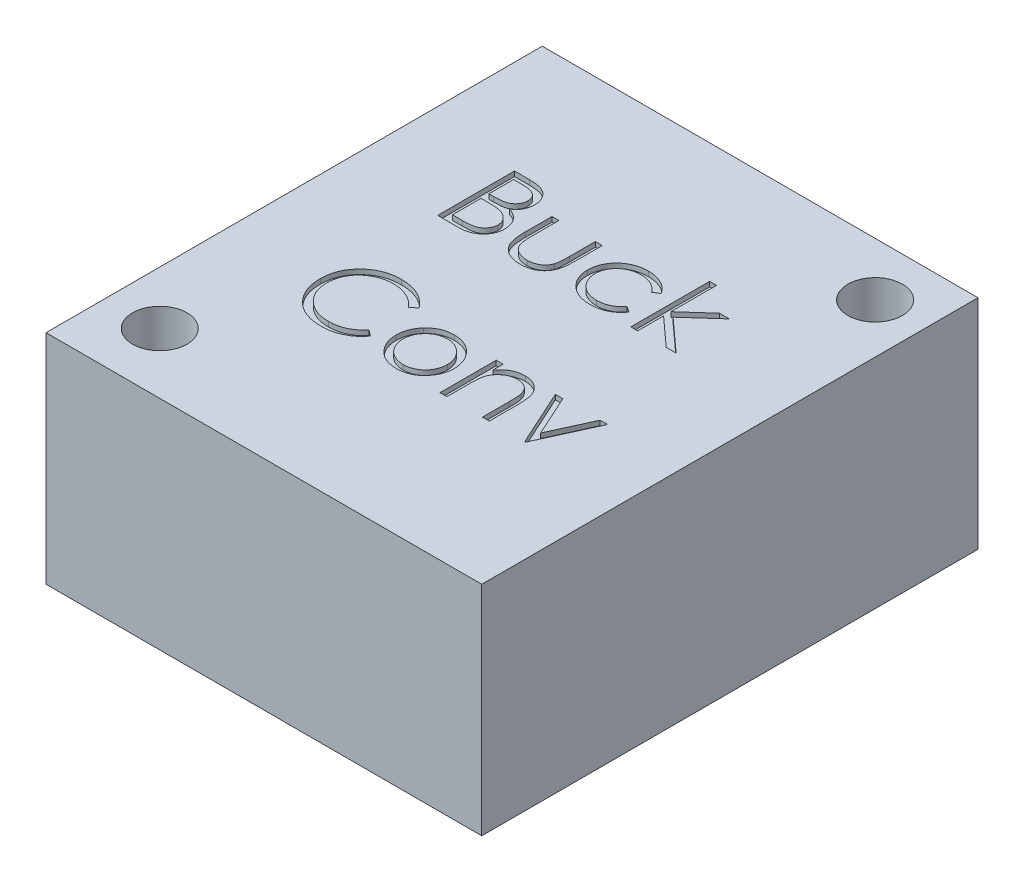
from build123d import *

# Parameters (mm, degrees)
SKETCH1_W           = 18
SKETCH1_H           = 20.5
SKETCH1_R           = 1.125
BOSS_EXTRUDE1_DEPTH = 9
CUT_EXTRUDE1_DEPTH  = 0.2


with BuildPart() as part:
    # Sketch1 → Boss-Extrude1 (new body)
    with BuildSketch(Plane(origin=(0, 0, 0), x_dir=(1, 0, 0), z_dir=(0, 1, 0))):
        Rectangle(SKETCH1_W, SKETCH1_H)
        with Locations((6.95, 8.05)):
            Circle(SKETCH1_R, mode=Mode.SUBTRACT)
        with Locations((-6.8, -7.75)):
            Circle(SKETCH1_R, mode=Mode.SUBTRACT)
    extrude(amount=BOSS_EXTRUDE1_DEPTH)

    # Sketch3 → Cut-Extrude1 (cut)
    with BuildSketch(Plane(origin=(0, 9, 0), x_dir=(1, 0, 0), z_dir=(0, 1, 0))):
        with BuildLine():
            Line((-5.106587344, 5.210805031), (-4.487106175, 5.210805031))
            add(Edge.make_bspline(
                [(-4.487106175, 5.210805031), (-4.456781769, 5.210645601), (-4.398005525, 5.210336584), (-4.312535031, 5.20554403), (-4.232480753, 5.199009272), (-4.157819474, 5.188640545), (-4.088585694, 5.176129433), (-4.024570766, 5.1609785), (-3.965978252, 5.1428115), (-3.896025984, 5.113922374), (-3.816269385, 5.070993499), (-3.729910843, 5.007558301), (-3.656065569, 4.929968138), (-3.592396552, 4.842444586), (-3.541776965, 4.746164279), (-3.505156245, 4.643422015), (-3.481971601, 4.535543006), (-3.479587236, 4.461480981), (-3.478382216, 4.424051225)],
                knots=[0, 0, 0, 0, 9.0959e-05, 0.000176302, 0.000256745, 0.000331852, 0.000402335, 0.000467743, 0.000529095, 0.000586142, 0.000694565, 0.000800018, 0.00090617, 0.001014562, 0.001123809, 0.001231237, 0.001341005, 0.001453163, 0.001453163, 0.001453163, 0.001453163], degree=3))
            add(Edge.make_bspline(
                [(-3.478382216, 4.424051225), (-3.479373922, 4.388987835), (-3.481322716, 4.320084968), (-3.499957933, 4.21930674), (-3.529132254, 4.123375277), (-3.569686301, 4.032640685), (-3.622393112, 3.94915305), (-3.684857444, 3.872238887), (-3.760219972, 3.805154714), (-3.816683483, 3.767650795), (-3.845364388, 3.748600504)],
                knots=[0, 0, 0, 0, 0.000105099, 0.000206529, 0.000306317, 0.000405381, 0.000503676, 0.000601724, 0.00070171, 0.000804929, 0.000804929, 0.000804929, 0.000804929], degree=3))
            add(Edge.make_bspline(
                [(-3.845364388, 3.748600504), (-3.809296, 3.734752969), (-3.740288239, 3.708259205), (-3.645323071, 3.661418463), (-3.563503461, 3.610471405), (-3.494200336, 3.554834656), (-3.434929749, 3.49486452), (-3.383174581, 3.429681667), (-3.33901362, 3.358435793), (-3.301174039, 3.281869729), (-3.271647667, 3.20076529), (-3.24953524, 3.115883229), (-3.236864768, 3.027527918), (-3.235061694, 2.96739761), (-3.234151447, 2.93704201)],
                knots=[0, 0, 0, 0, 0.000115862, 0.000221672, 0.000317136, 0.000404447, 0.000487649, 0.000569596, 0.000653599, 0.000738647, 0.000825372, 0.000912066, 0.001001383, 0.001092443, 0.001092443, 0.001092443, 0.001092443], degree=3))
            add(Edge.make_bspline(
                [(-3.234151447, 2.93704201), (-3.235037586, 2.906047776), (-3.236781089, 2.845065753), (-3.249644349, 2.755480738), (-3.271424039, 2.669869179), (-3.301424293, 2.587677335), (-3.340578679, 2.509064213), (-3.388229046, 2.433940752), (-3.445044822, 2.363061752), (-3.508601853, 2.295639608), (-3.580503942, 2.235017258), (-3.658078948, 2.18102801), (-3.742303824, 2.136626939), (-3.831795276, 2.099328834), (-3.927557191, 2.070838018), (-4.029159557, 2.050905755), (-4.136514745, 2.037475471), (-4.21018359, 2.036371293), (-4.247963546, 2.035805031)],
                knots=[0, 0, 0, 0, 9.2965e-05, 0.000182912, 0.000270839, 0.000357564, 0.000444886, 0.000533812, 0.000623905, 0.000717027, 0.000811331, 0.000905539, 0.001000006, 0.001096388, 0.001195991, 0.001299146, 0.001406751, 0.001520027, 0.001520027, 0.001520027, 0.001520027], degree=3))
            Line((-4.247963546, 2.035805031), (-5.106587344, 2.035805031))
            Line((-5.106587344, 2.035805031), (-5.106587344, 5.210805031))
        make_face()
        with BuildLine():
            Line((-4.821651447, 4.885164006), (-4.821651447, 3.867535801))
            Line((-4.821651447, 3.867535801), (-4.630210141, 3.867535801))
            add(Edge.make_bspline(
                [(-4.630210141, 3.867535801), (-4.602225877, 3.867898588), (-4.548154575, 3.868599567), (-4.469850097, 3.870607543), (-4.397165259, 3.876230054), (-4.330225525, 3.881850949), (-4.269136308, 3.890990039), (-4.214032948, 3.901868608), (-4.164050649, 3.913373814), (-4.106411205, 3.93294042), (-4.041030744, 3.961858026), (-3.971332142, 4.006736048), (-3.909887302, 4.060188855), (-3.858001282, 4.12186637), (-3.815536591, 4.189780696), (-3.786042006, 4.262848223), (-3.76604197, 4.339247914), (-3.764235367, 4.391697329), (-3.763318114, 4.418327067)],
                knots=[0, 0, 0, 0, 8.3964e-05, 0.000162235, 0.00023492, 0.000302637, 0.000363711, 0.000420091, 0.000471151, 0.00051741, 0.000602525, 0.000684916, 0.00076515, 0.000845934, 0.000925893, 0.001004319, 0.001081603, 0.001161311, 0.001161311, 0.001161311, 0.001161311], degree=3))
            add(Edge.make_bspline(
                [(-3.763318114, 4.418327067), (-3.763795434, 4.435949016), (-3.764731751, 4.470516395), (-3.772400104, 4.520907595), (-3.785433546, 4.568300142), (-3.802174227, 4.613343514), (-3.825568251, 4.654629264), (-3.85311225, 4.693584877), (-3.886391412, 4.728883727), (-3.92427126, 4.761876058), (-3.967821939, 4.791126451), (-4.017017468, 4.816744857), (-4.072523433, 4.837373991), (-4.13340438, 4.855440786), (-4.200597438, 4.868130167), (-4.273327211, 4.878701454), (-4.35218942, 4.884083299), (-4.406749621, 4.884795735), (-4.434952729, 4.885164006)],
                knots=[0, 0, 0, 0, 5.2851e-05, 0.000103672, 0.000152426, 0.000200145, 0.000247403, 0.000294352, 0.000342957, 0.000392558, 0.000444773, 0.00049996, 0.000558547, 0.000622148, 0.000690253, 0.000763469, 0.000842543, 0.000927155, 0.000927155, 0.000927155, 0.000927155], degree=3))
            Line((-4.434952729, 4.885164006), (-4.821651447, 4.885164006))
        make_face(mode=Mode.SUBTRACT)
        with BuildLine():
            Line((-4.821651447, 3.541894775), (-4.821651447, 2.361446057))
            Line((-4.821651447, 2.361446057), (-4.4158722, 2.361446057))
            add(Edge.make_bspline(
                [(-4.4158722, 2.361446057), (-4.38682646, 2.361794171), (-4.330844626, 2.362465114), (-4.250017081, 2.36465546), (-4.175102409, 2.369637739), (-4.106442457, 2.377480759), (-4.043295832, 2.385988352), (-3.986420058, 2.397428586), (-3.93535409, 2.410535857), (-3.876140968, 2.430796142), (-3.809462786, 2.462270798), (-3.737607223, 2.509727275), (-3.673720582, 2.566263418), (-3.619468669, 2.631696462), (-3.575006886, 2.70284488), (-3.542662295, 2.77826959), (-3.522713446, 2.856724318), (-3.520298478, 2.910215551), (-3.519087344, 2.93704201)],
                knots=[0, 0, 0, 0, 8.7144e-05, 0.000167958, 0.000242546, 0.000312291, 0.000375253, 0.000433628, 0.000486234, 0.000533299, 0.000621212, 0.00070659, 0.000790835, 0.000876178, 0.000960721, 0.001041645, 0.001121551, 0.001201941, 0.001201941, 0.001201941, 0.001201941], degree=3))
            add(Edge.make_bspline(
                [(-3.519087344, 2.93704201), (-3.519337811, 2.953818112), (-3.519834703, 2.987099716), (-3.52732826, 3.036009066), (-3.538226557, 3.083385394), (-3.552315786, 3.129357344), (-3.572834874, 3.173093764), (-3.596789383, 3.215459657), (-3.624875797, 3.256511028), (-3.668640147, 3.308410715), (-3.732296162, 3.368206863), (-3.822744451, 3.426751597), (-3.925589321, 3.473966393), (-4.000181404, 3.494013775), (-4.038713747, 3.504369735)],
                knots=[0, 0, 0, 0, 5.0282e-05, 9.9752e-05, 0.000148043, 0.000196116, 0.000243648, 0.000292638, 0.000342035, 0.000392605, 0.000496106, 0.000602654, 0.000714508, 0.000834032, 0.000834032, 0.000834032, 0.000834032], degree=3))
            add(Edge.make_bspline(
                [(-4.038713747, 3.504369735), (-4.054161569, 3.50750399), (-4.087655635, 3.5142997), (-4.142272512, 3.521473117), (-4.204625764, 3.527863993), (-4.274859374, 3.532591257), (-4.353062202, 3.537477622), (-4.439401264, 3.539377924), (-4.53352397, 3.54164511), (-4.598831337, 3.541809424), (-4.632754211, 3.541894775)],
                knots=[0, 0, 0, 0, 4.7275e-05, 0.000102503, 0.000165156, 0.000235303, 0.00031366, 0.000400195, 0.000494345, 0.00059611, 0.00059611, 0.00059611, 0.00059611], degree=3))
            Line((-4.632754211, 3.541894775), (-4.821651447, 3.541894775))
        make_face(mode=Mode.SUBTRACT)
        with BuildLine():
            Line((-2.70498478, 4.355997339), (-2.420048883, 4.355997339))
            Line((-2.420048883, 4.355997339), (-2.420048883, 3.279855512))
            add(Edge.make_bspline(
                [(-2.420048883, 3.279855512), (-2.419920155, 3.248266304), (-2.419673904, 3.187837628), (-2.418003908, 3.10088328), (-2.414075894, 3.021583834), (-2.409164782, 2.94989348), (-2.40284913, 2.885824346), (-2.395334939, 2.829600215), (-2.386936228, 2.780583491), (-2.378715051, 2.751062018), (-2.374891631, 2.737332475)],
                knots=[0, 0, 0, 0, 9.4769e-05, 0.000181288, 0.000260882, 0.000332932, 0.000396851, 0.000453969, 0.000503119, 0.000545851, 0.000545851, 0.000545851, 0.000545851], degree=3))
            add(Edge.make_bspline(
                [(-2.374891631, 2.737332475), (-2.368758026, 2.720076014), (-2.356618331, 2.685921848), (-2.334598813, 2.636583251), (-2.307358822, 2.590885673), (-2.277550264, 2.547066979), (-2.243170087, 2.506425176), (-2.204653281, 2.469028898), (-2.163289166, 2.433465187), (-2.101825681, 2.391387554), (-2.017770489, 2.346288647), (-1.907414061, 2.307376012), (-1.787758085, 2.284120661), (-1.705058661, 2.281422587), (-1.662551888, 2.280035801)],
                knots=[0, 0, 0, 0, 5.4937e-05, 0.000108733, 0.000161748, 0.000214322, 0.000267581, 0.000321101, 0.000375256, 0.000431008, 0.000544257, 0.000660328, 0.000780822, 0.000908255, 0.000908255, 0.000908255, 0.000908255], degree=3))
            add(Edge.make_bspline(
                [(-1.662551888, 2.280035801), (-1.620049063, 2.281452076), (-1.537813961, 2.284192307), (-1.419472667, 2.306674517), (-1.311294599, 2.344235392), (-1.214365521, 2.396674973), (-1.129125081, 2.46084813), (-1.058091786, 2.536148978), (-0.999483777, 2.620195207), (-0.973893802, 2.682900803), (-0.961024444, 2.714435841)],
                knots=[0, 0, 0, 0, 0.000127432, 0.000246558, 0.000359807, 0.000469652, 0.000575869, 0.000678443, 0.000779171, 0.000881077, 0.000881077, 0.000881077, 0.000881077], degree=3))
            add(Edge.make_bspline(
                [(-0.961024444, 2.714435841), (-0.957219678, 2.727105269), (-0.94880827, 2.75511428), (-0.939770994, 2.802630195), (-0.931629875, 2.859294514), (-0.92467828, 2.925478032), (-0.919720596, 3.001007792), (-0.917048129, 3.08586019), (-0.914028908, 3.179768852), (-0.913983083, 3.245507462), (-0.913959139, 3.279855512)],
                knots=[0, 0, 0, 0, 3.9663e-05, 8.7686e-05, 0.000144892, 0.000211407, 0.000287264, 0.000371914, 0.000466079, 0.000569116, 0.000569116, 0.000569116, 0.000569116], degree=3))
            Line((-0.913959139, 3.279855512), (-0.913959139, 4.355997339))
            Line((-0.913959139, 4.355997339), (-0.629023242, 4.355997339))
            Line((-0.629023242, 4.355997339), (-0.629023242, 3.226430031))
            add(Edge.make_bspline(
                [(-0.629023242, 3.226430031), (-0.629423922, 3.188051383), (-0.630201297, 3.113591555), (-0.635197244, 3.005383825), (-0.643769393, 2.904543789), (-0.656780257, 2.811018068), (-0.672079833, 2.724878067), (-0.691815881, 2.646013384), (-0.715381854, 2.574667003), (-0.741966142, 2.509586962), (-0.773373122, 2.450580137), (-0.806780491, 2.394576932), (-0.845356534, 2.342966912), (-0.885969532, 2.293180973), (-0.931146748, 2.247695445), (-0.98004162, 2.205466606), (-1.031965951, 2.165848927), (-1.088072009, 2.130387552), (-1.147540724, 2.098441024), (-1.210445508, 2.070123582), (-1.277556842, 2.047714815), (-1.348008856, 2.028382997), (-1.42214672, 2.013220586), (-1.499898962, 2.002528486), (-1.581239393, 1.995974079), (-1.636674402, 1.995396188), (-1.665095958, 1.995099903)],
                knots=[0, 0, 0, 0, 0.000115135, 0.000223378, 0.000324896, 0.000418621, 0.000506569, 0.000587246, 0.000662266, 0.000731837, 0.000797836, 0.000862628, 0.000927252, 0.000990933, 0.001055247, 0.001119267, 0.00118465, 0.001250991, 0.001318148, 0.001387052, 0.00145765, 0.001530167, 0.001606131, 0.001684475, 0.001765499, 0.001850747, 0.001850747, 0.001850747, 0.001850747], degree=3))
            add(Edge.make_bspline(
                [(-1.665095958, 1.995099903), (-1.693304939, 1.995408066), (-1.748738212, 1.996013635), (-1.830082841, 2.002492275), (-1.908050505, 2.013203972), (-1.982364009, 2.028494062), (-2.053097927, 2.047579504), (-2.120538773, 2.070261283), (-2.183896862, 2.09845572), (-2.243933395, 2.130185361), (-2.300178418, 2.166076718), (-2.3528912, 2.205417726), (-2.402001059, 2.248149654), (-2.447518828, 2.294094043), (-2.488805599, 2.343820835), (-2.526375866, 2.396930022), (-2.56080802, 2.452895374), (-2.591970908, 2.5128241), (-2.618742286, 2.57865728), (-2.642378116, 2.651498218), (-2.66170991, 2.732145501), (-2.677442006, 2.820530179), (-2.690097956, 2.916229252), (-2.69888467, 3.019796315), (-2.703797603, 3.130979093), (-2.704580523, 3.207768636), (-2.70498478, 3.247418613)],
                knots=[0, 0, 0, 0, 8.4612e-05, 0.00016627, 0.000244614, 0.000320578, 0.000393709, 0.000464306, 0.000533793, 0.00060151, 0.000667851, 0.000733743, 0.00079866, 0.000862973, 0.00092755, 0.000992318, 0.001057985, 0.001124549, 0.001194707, 0.001270936, 0.001354082, 0.001443281, 0.001540158, 0.001643577, 0.001754997, 0.001873947, 0.001873947, 0.001873947, 0.001873947], degree=3))
            Line((-2.70498478, 3.247418613), (-2.70498478, 4.355997339))
        make_face()
        with BuildLine():
            Line((2.301745989, 3.852907395), (2.063239378, 3.704715288))
            add(Edge.make_bspline(
                [(2.063239378, 3.704715288), (2.037086572, 3.737216759), (1.985609213, 3.801190388), (1.896220048, 3.883749399), (1.800959694, 3.954658072), (1.698200322, 4.012446475), (1.588086061, 4.057097362), (1.47105116, 4.088693334), (1.347112309, 4.108382183), (1.262144593, 4.110619957), (1.218607968, 4.11176657)],
                knots=[0, 0, 0, 0, 0.000125005, 0.00024605, 0.000363844, 0.000480601, 0.000598709, 0.000719366, 0.000843592, 0.000974131, 0.000974131, 0.000974131, 0.000974131], degree=3))
            add(Edge.make_bspline(
                [(1.218607968, 4.11176657), (1.183810914, 4.110807863), (1.115279063, 4.108919716), (1.014671338, 4.09711734), (0.918838632, 4.075670661), (0.827180275, 4.047412293), (0.740348181, 4.009538816), (0.658114848, 3.963447108), (0.579750867, 3.909880286), (0.507527109, 3.847822148), (0.441460796, 3.780331928), (0.384221066, 3.707983933), (0.33438542, 3.632945175), (0.295282159, 3.553341809), (0.263282541, 3.47099496), (0.24223073, 3.384350248), (0.228202042, 3.294517699), (0.226597008, 3.233268919), (0.22578445, 3.202261361)],
                knots=[0, 0, 0, 0, 0.000104402, 0.000205617, 0.000303301, 0.000398648, 0.000492936, 0.000586896, 0.000681104, 0.000777202, 0.000872105, 0.000963985, 0.0010536, 0.001141775, 0.001229541, 0.001318085, 0.001408752, 0.001501717, 0.001501717, 0.001501717, 0.001501717], degree=3))
            add(Edge.make_bspline(
                [(0.22578445, 3.202261361), (0.227398486, 3.161649291), (0.23060481, 3.080972364), (0.255733992, 2.961884372), (0.296867847, 2.846746452), (0.353163183, 2.736376071), (0.424353155, 2.634237087), (0.507966837, 2.542630668), (0.604050577, 2.463331842), (0.711757763, 2.397588909), (0.82855943, 2.344737525), (0.953191882, 2.307084445), (1.084636683, 2.284358364), (1.174631375, 2.281495473), (1.220516021, 2.280035801)],
                knots=[0, 0, 0, 0, 0.00012176, 0.00024188, 0.000363385, 0.000487688, 0.000612427, 0.000735772, 0.000858657, 0.000984866, 0.001113248, 0.001242216, 0.001374486, 0.001512078, 0.001512078, 0.001512078, 0.001512078], degree=3))
            add(Edge.make_bspline(
                [(1.220516021, 2.280035801), (1.262566795, 2.28121463), (1.345207726, 2.283531343), (1.466009477, 2.303061188), (1.581016968, 2.335032199), (1.69022611, 2.379616139), (1.793437346, 2.437244671), (1.889983812, 2.508327633), (1.981786613, 2.59082012), (2.035758871, 2.654608566), (2.063239378, 2.687087083)],
                knots=[0, 0, 0, 0, 0.000126092, 0.000247804, 0.000366009, 0.000483528, 0.00060084, 0.00071966, 0.000842576, 0.00097008, 0.00097008, 0.00097008, 0.00097008], degree=3))
            Line((2.063239378, 2.687087083), (2.301745989, 2.530626746))
            add(Edge.make_bspline(
                [(2.301745989, 2.530626746), (2.287605716, 2.509861587), (2.259372104, 2.46840019), (2.212175615, 2.40994017), (2.161266911, 2.355219787), (2.106844601, 2.30431239), (2.0496193, 2.255999758), (1.987636125, 2.212591544), (1.922893691, 2.171647812), (1.854631955, 2.134806135), (1.783556679, 2.101689686), (1.709767874, 2.07321341), (1.633586187, 2.048747671), (1.554922046, 2.029300935), (1.473620367, 2.01377896), (1.389891413, 2.003479531), (1.303764021, 1.99579124), (1.245550712, 1.995332347), (1.216063898, 1.995099903)],
                knots=[0, 0, 0, 0, 7.5343e-05, 0.000150436, 0.000225141, 0.000299381, 0.000373893, 0.000449603, 0.000526189, 0.000603598, 0.000682135, 0.00076127, 0.000840722, 0.000922015, 0.001004219, 0.001088867, 0.001175014, 0.001263441, 0.001263441, 0.001263441, 0.001263441], degree=3))
            add(Edge.make_bspline(
                [(1.216063898, 1.995099903), (1.171059739, 1.995908421), (1.082851261, 1.997493123), (0.953744415, 2.014917954), (0.830360588, 2.041186649), (0.712741935, 2.078890893), (0.600870144, 2.127427368), (0.494849529, 2.186715426), (0.395031141, 2.257247407), (0.302402074, 2.337767919), (0.217328905, 2.425071929), (0.144280147, 2.51927864), (0.080920508, 2.616924448), (0.030041094, 2.720165947), (-0.010460046, 2.827630963), (-0.038132287, 2.940180395), (-0.056029978, 3.056886368), (-0.058101329, 3.136472626), (-0.059151447, 3.176820656)],
                knots=[0, 0, 0, 0, 0.000134932, 0.000264467, 0.000390091, 0.000512988, 0.000634334, 0.000755353, 0.000876757, 0.001000312, 0.001123109, 0.001241815, 0.001357376, 0.001471719, 0.001586432, 0.001701199, 0.001818851, 0.001939829, 0.001939829, 0.001939829, 0.001939829], degree=3))
            add(Edge.make_bspline(
                [(-0.059151447, 3.176820656), (-0.058751382, 3.204196808), (-0.057955588, 3.258652491), (-0.048827982, 3.339474445), (-0.03703651, 3.419220054), (-0.01705602, 3.496878485), (0.006022267, 3.573627569), (0.035482214, 3.64854224), (0.070040179, 3.721970621), (0.109275874, 3.793723562), (0.153443522, 3.862620644), (0.202321498, 3.927711468), (0.25406886, 3.98977797), (0.311106476, 4.046677381), (0.371013876, 4.100685212), (0.435485948, 4.150358654), (0.504152899, 4.195843695), (0.575983485, 4.237981402), (0.650935902, 4.275500318), (0.728557095, 4.307824756), (0.808379343, 4.335449592), (0.890530331, 4.357319826), (0.974464788, 4.375659917), (1.060844145, 4.387196821), (1.149337947, 4.395348654), (1.209260196, 4.396247444), (1.23959655, 4.396702467)],
                knots=[0, 0, 0, 0, 8.2086e-05, 0.000163282, 0.000243795, 0.000323701, 0.000403569, 0.00048412, 0.000564924, 0.000646901, 0.000729292, 0.000810194, 0.000890978, 0.000971482, 0.00105166, 0.001132824, 0.001215379, 0.00129861, 0.001382518, 0.00146662, 0.001550694, 0.001635707, 0.001721529, 0.001808238, 0.001896973, 0.001987959, 0.001987959, 0.001987959, 0.001987959], degree=3))
            add(Edge.make_bspline(
                [(1.23959655, 4.396702467), (1.277587791, 4.39586618), (1.353380374, 4.394197787), (1.465812301, 4.380156438), (1.576588227, 4.358986974), (1.683764528, 4.327624479), (1.786041723, 4.289648163), (1.881777453, 4.247000915), (1.968718119, 4.19747581), (2.048481003, 4.143301135), (2.12121528, 4.08219517), (2.187667569, 4.01342743), (2.249200565, 3.93735581), (2.284086296, 3.881289182), (2.301745989, 3.852907395)],
                knots=[0, 0, 0, 0, 0.000113934, 0.000227299, 0.000339435, 0.00045196, 0.000561834, 0.000666582, 0.000765982, 0.000861599, 0.000955493, 0.001050396, 0.001148136, 0.001248336, 0.001248336, 0.001248336, 0.001248336], degree=3))
        make_face()
        Polygon((2.871617784, 5.292215288), (3.156553681, 5.292215288), (3.156553681, 3.409603108), (4.212342944, 4.355997339), (4.621938297, 4.355997339), (3.396968345, 3.256958877), (4.744053681, 2.035805031), (4.335094346, 2.035805031), (3.156553681, 3.104950664), (3.156553681, 2.035805031), (2.871617784, 2.035805031), align=None)
        with BuildLine():
            Line((-2.175818114, -1.663453783), (-2.425137024, -1.854259071))
            add(Edge.make_bspline(
                [(-2.425137024, -1.854259071), (-2.442922366, -1.833062799), (-2.478253264, -1.790956025), (-2.535094112, -1.731828867), (-2.594332031, -1.676433951), (-2.655944376, -1.624507389), (-2.721040149, -1.577865037), (-2.788042445, -1.534076251), (-2.8580721, -1.494826231), (-2.954911174, -1.447234808), (-3.081591722, -1.397572225), (-3.241062754, -1.355931436), (-3.407533537, -1.329423656), (-3.521105645, -1.326552692), (-3.578873002, -1.325092405)],
                knots=[0, 0, 0, 0, 8.299e-05, 0.000164861, 0.000245858, 0.000326233, 0.000406381, 0.000485944, 0.000566254, 0.000647036, 0.000809554, 0.000973391, 0.001140702, 0.001313896, 0.001313896, 0.001313896, 0.001313896], degree=3))
            add(Edge.make_bspline(
                [(-3.578873002, -1.325092405), (-3.610698566, -1.325458856), (-3.674054323, -1.326188359), (-3.768078296, -1.335812351), (-3.860346564, -1.349338949), (-3.950799108, -1.369409777), (-4.039320792, -1.394784939), (-4.126490328, -1.425106565), (-4.211045658, -1.462621312), (-4.294156488, -1.504085234), (-4.373784772, -1.550918701), (-4.449127566, -1.602002956), (-4.51991008, -1.656766351), (-4.586188306, -1.71541414), (-4.648030002, -1.777682204), (-4.704987063, -1.844234143), (-4.756862399, -1.914857186), (-4.804684272, -1.988620063), (-4.847512966, -2.065307917), (-4.883372214, -2.145204588), (-4.91512686, -2.226941881), (-4.94025403, -2.311443291), (-4.960142699, -2.398114229), (-4.973865651, -2.487187301), (-4.983380192, -2.578476425), (-4.984106067, -2.640352015), (-4.98447196, -2.671541723)],
                knots=[0, 0, 0, 0, 9.5437e-05, 0.000189987, 0.000283265, 0.000375086, 0.000467691, 0.000559419, 0.000651703, 0.000744998, 0.000837935, 0.000928607, 0.001017915, 0.001106228, 0.001193927, 0.001280987, 0.00136876, 0.001456615, 0.001544584, 0.001631962, 0.001719133, 0.001807466, 0.001896183, 0.00198569, 0.002077709, 0.002171238, 0.002171238, 0.002171238, 0.002171238], degree=3))
            add(Edge.make_bspline(
                [(-4.98447196, -2.671541723), (-4.98332731, -2.718469421), (-4.981079941, -2.81060573), (-4.961078952, -2.945561927), (-4.930685048, -3.074848538), (-4.885132346, -3.197657395), (-4.828962922, -3.315502834), (-4.75798751, -3.426390937), (-4.675785365, -3.531997392), (-4.58119357, -3.629826351), (-4.477411152, -3.719192374), (-4.36606126, -3.797887544), (-4.247421228, -3.863487473), (-4.122800999, -3.918075653), (-3.991241596, -3.960037113), (-3.852979596, -3.989577425), (-3.708315715, -4.008847118), (-3.609464902, -4.010691963), (-3.559156455, -4.011630866)],
                knots=[0, 0, 0, 0, 0.000140704, 0.000276253, 0.000408455, 0.000538433, 0.000668431, 0.000799358, 0.000932567, 0.001069312, 0.00120687, 0.001342915, 0.001477586, 0.00161288, 0.00175046, 0.001891054, 0.002036604, 0.002187448, 0.002187448, 0.002187448, 0.002187448], degree=3))
            add(Edge.make_bspline(
                [(-3.559156455, -4.011630866), (-3.503727587, -4.010098902), (-3.394630315, -4.007083629), (-3.23463932, -3.981539167), (-3.081481161, -3.940120913), (-2.935147601, -3.882156369), (-2.796051172, -3.806804287), (-2.663974201, -3.715456927), (-2.538805205, -3.607245368), (-2.463538399, -3.524619958), (-2.425137024, -3.482464199)],
                knots=[0, 0, 0, 0, 0.000166206, 0.000327134, 0.000484664, 0.00064139, 0.000798189, 0.000958205, 0.001122325, 0.001293282, 0.001293282, 0.001293282, 0.001293282], degree=3))
            Line((-2.425137024, -3.482464199), (-2.175818114, -3.671361435))
            add(Edge.make_bspline(
                [(-2.175818114, -3.671361435), (-2.195882399, -3.697249888), (-2.235914863, -3.748902789), (-2.300737493, -3.821720697), (-2.369024755, -3.890213644), (-2.441283864, -3.953829415), (-2.516683575, -4.013840965), (-2.596577744, -4.068543341), (-2.67991608, -4.118700072), (-2.766416215, -4.164625925), (-2.855986242, -4.205372284), (-2.948518837, -4.240255345), (-3.043615144, -4.270304352), (-3.141279513, -4.295025752), (-3.241714521, -4.314321664), (-3.344557737, -4.32722094), (-3.450031123, -4.336058248), (-3.521188698, -4.336863715), (-3.557248402, -4.337271892)],
                knots=[0, 0, 0, 0, 9.8237e-05, 0.000196004, 0.000292247, 0.000388218, 0.000484669, 0.00058117, 0.000678466, 0.000776338, 0.000874822, 0.000973456, 0.001072826, 0.001173865, 0.001275526, 0.001379423, 0.001484691, 0.001592844, 0.001592844, 0.001592844, 0.001592844], degree=3))
            add(Edge.make_bspline(
                [(-3.557248402, -4.337271892), (-3.591396586, -4.337034227), (-3.65892039, -4.336564275), (-3.758614258, -4.32895138), (-3.855669092, -4.318564833), (-3.949807503, -4.302925571), (-4.041543209, -4.284470348), (-4.130044596, -4.259731423), (-4.216182537, -4.232018964), (-4.29961096, -4.199448012), (-4.380400831, -4.162694047), (-4.458291574, -4.121154561), (-4.533247366, -4.075178869), (-4.606005141, -4.025780396), (-4.675490092, -3.971372415), (-4.742304361, -3.912710539), (-4.806822607, -3.849992487), (-4.846739329, -3.804767012), (-4.866808699, -3.782028502)],
                knots=[0, 0, 0, 0, 0.000102417, 0.000202516, 0.000299794, 0.000395154, 0.000488707, 0.000580357, 0.000670665, 0.000760075, 0.000848874, 0.000936794, 0.001024712, 0.001112565, 0.001200478, 0.001289268, 0.001379219, 0.001470177, 0.001470177, 0.001470177, 0.001470177], degree=3))
            add(Edge.make_bspline(
                [(-4.866808699, -3.782028502), (-4.89895389, -3.742530424), (-4.962856186, -3.664011122), (-5.044613056, -3.536751696), (-5.11459691, -3.403884107), (-5.171180781, -3.264710314), (-5.215415546, -3.119542613), (-5.246059916, -2.968307825), (-5.265973157, -2.811147192), (-5.268250348, -2.704252391), (-5.269407857, -2.649917124)],
                knots=[0, 0, 0, 0, 0.000152677, 0.000303511, 0.000452867, 0.000602629, 0.000753527, 0.000907451, 0.001065071, 0.001228016, 0.001228016, 0.001228016, 0.001228016], degree=3))
            add(Edge.make_bspline(
                [(-5.269407857, -2.649917124), (-5.267997075, -2.592807534), (-5.265221448, -2.480447981), (-5.241639547, -2.315553038), (-5.203703925, -2.15757284), (-5.149822462, -2.006802301), (-5.08150975, -1.862448403), (-4.997121322, -1.725613882), (-4.897637557, -1.595423642), (-4.783838692, -1.473853118), (-4.659045467, -1.362692419), (-4.525406257, -1.264896792), (-4.383182634, -1.183510188), (-4.23394144, -1.115477955), (-4.076565143, -1.063186192), (-3.911389515, -1.026580087), (-3.738724928, -1.003795274), (-3.620921156, -1.000914907), (-3.561064508, -0.999451379)],
                knots=[0, 0, 0, 0, 0.000171259, 0.000336941, 0.000498606, 0.000657931, 0.000816392, 0.000976852, 0.001139297, 0.001307149, 0.001475639, 0.001640004, 0.001802988, 0.001966374, 0.002131298, 0.002299486, 0.002473278, 0.002652798, 0.002652798, 0.002652798, 0.002652798], degree=3))
            add(Edge.make_bspline(
                [(-3.561064508, -0.999451379), (-3.524584237, -0.999888747), (-3.452375214, -1.000754473), (-3.345556737, -1.009196474), (-3.241559769, -1.023269531), (-3.140312664, -1.042424823), (-3.041322862, -1.066198607), (-2.945346929, -1.097168735), (-2.851821692, -1.132580446), (-2.761336996, -1.173364197), (-2.674326983, -1.219144741), (-2.590818751, -1.269414628), (-2.511475629, -1.324111537), (-2.435739317, -1.382770275), (-2.364876754, -1.446631825), (-2.296875984, -1.513939644), (-2.234046292, -1.58663247), (-2.195263036, -1.637799803), (-2.175818114, -1.663453783)],
                knots=[0, 0, 0, 0, 0.000109425, 0.000216595, 0.000321206, 0.000424117, 0.000525619, 0.000626393, 0.000726442, 0.000825506, 0.000923941, 0.001021237, 0.001117738, 0.001212903, 0.001308399, 0.001403742, 0.001499772, 0.001596332, 0.001596332, 0.001596332, 0.001596332], degree=3))
        make_face()
        with BuildLine():
            add(Edge.make_bspline(
                [(-0.485283258, -1.894964199), (-0.441748318, -1.895891201), (-0.356386939, -1.897708824), (-0.2313755, -1.917135257), (-0.112045269, -1.946841794), (0.002060777, -1.987909569), (0.109481273, -2.042956767), (0.211780902, -2.108642338), (0.308679188, -2.186459405), (0.366757222, -2.246655653), (0.396237175, -2.277210794)],
                knots=[0, 0, 0, 0, 0.000130509, 0.000255897, 0.000378531, 0.000499054, 0.000618803, 0.000739829, 0.000863296, 0.000990571, 0.000990571, 0.000990571, 0.000990571], degree=3))
            add(Edge.make_bspline(
                [(0.396237175, -2.277210794), (0.421620805, -2.306433481), (0.471896821, -2.364313316), (0.53636358, -2.458162336), (0.591900281, -2.555353713), (0.636407396, -2.657178074), (0.671500239, -2.762746525), (0.696415549, -2.872421921), (0.711235483, -2.98596205), (0.713233888, -3.063072675), (0.714245989, -3.102125658)],
                knots=[0, 0, 0, 0, 0.000116043, 0.000229841, 0.000340916, 0.00045141, 0.000562633, 0.000674184, 0.000788337, 0.000905475, 0.000905475, 0.000905475, 0.000905475], degree=3))
            add(Edge.make_bspline(
                [(0.714245989, -3.102125658), (0.713355776, -3.141404996), (0.711596673, -3.2190228), (0.694956392, -3.333340367), (0.669074622, -3.444188528), (0.632034311, -3.5511032), (0.584538027, -3.654411193), (0.526580046, -3.753661284), (0.45775365, -3.849049291), (0.379735739, -3.939765244), (0.293510108, -4.023373168), (0.199969031, -4.096242384), (0.100950729, -4.158673338), (-0.004861456, -4.208962086), (-0.116501248, -4.248613029), (-0.234209445, -4.276462329), (-0.357803187, -4.293300428), (-0.442192167, -4.29546267), (-0.485283258, -4.296566764)],
                knots=[0, 0, 0, 0, 0.000117773, 0.000232725, 0.000345804, 0.000458844, 0.000571541, 0.000686407, 0.000803078, 0.000923941, 0.00104494, 0.001162753, 0.001279048, 0.001395399, 0.001513481, 0.001633808, 0.001757668, 0.001886907, 0.001886907, 0.001886907, 0.001886907], degree=3))
            add(Edge.make_bspline(
                [(-0.485283258, -4.296566764), (-0.528585468, -4.295458964), (-0.613395033, -4.293289283), (-0.737425031, -4.276527748), (-0.855344186, -4.248625864), (-0.967130129, -4.208831781), (-1.07339724, -4.158671731), (-1.172989276, -4.096431127), (-1.266606342, -4.023351557), (-1.352850214, -3.9397711), (-1.430863235, -3.849047782), (-1.499690892, -3.753661676), (-1.557648545, -3.654411091), (-1.605144916, -3.551103227), (-1.642185203, -3.44418852), (-1.66806698, -3.333340369), (-1.684707259, -3.219022799), (-1.686466362, -3.141404996), (-1.687356575, -3.102125658)],
                knots=[0, 0, 0, 0, 0.000129874, 0.000254364, 0.000374691, 0.000492773, 0.000609698, 0.000726534, 0.000844346, 0.000965345, 0.001086209, 0.001202879, 0.001317745, 0.001430442, 0.001543482, 0.001656561, 0.001771513, 0.001889286, 0.001889286, 0.001889286, 0.001889286], degree=3))
            add(Edge.make_bspline(
                [(-1.687356575, -3.102125658), (-1.686337572, -3.063284934), (-1.684320122, -2.986386976), (-1.669515088, -2.873060285), (-1.644696969, -2.763570511), (-1.60956206, -2.658409544), (-1.564644708, -2.557031398), (-1.509888397, -2.459599873), (-1.444764037, -2.366175225), (-1.394687981, -2.308370195), (-1.369347761, -2.279118847)],
                knots=[0, 0, 0, 0, 0.000116502, 0.000230655, 0.000342206, 0.000452826, 0.000562738, 0.000674367, 0.000787643, 0.000903686, 0.000903686, 0.000903686, 0.000903686], degree=3))
            add(Edge.make_bspline(
                [(-1.369347761, -2.279118847), (-1.339912254, -2.248298723), (-1.282022148, -2.187685528), (-1.184641517, -2.110095309), (-1.082593551, -2.043042871), (-0.973985939, -1.989089447), (-0.859973632, -1.94660022), (-0.740031891, -1.917058646), (-0.614596245, -1.897778816), (-0.52881716, -1.895911755), (-0.485283258, -1.894964199)],
                knots=[0, 0, 0, 0, 0.000127724, 0.000251192, 0.000372563, 0.000493448, 0.000614191, 0.000736825, 0.000863471, 0.00099398, 0.00099398, 0.00099398, 0.00099398], degree=3))
        make_face()
        with BuildLine():
            add(Edge.make_bspline(
                [(-0.486555293, -2.179900097), (-0.517341555, -2.180775119), (-0.578119336, -2.182502576), (-0.667581388, -2.195641546), (-0.75370567, -2.216458211), (-0.836655579, -2.246034748), (-0.916151385, -2.284224463), (-0.9922692, -2.331131333), (-1.065232914, -2.386134086), (-1.133615214, -2.449146652), (-1.196373454, -2.51797974), (-1.251235619, -2.591320752), (-1.297885537, -2.66798008), (-1.336747681, -2.748037443), (-1.365692059, -2.832304133), (-1.3867133, -2.919825848), (-1.399839876, -3.010780904), (-1.401551091, -3.072612685), (-1.402420678, -3.104033711)],
                knots=[0, 0, 0, 0, 9.233e-05, 0.000182276, 0.000270667, 0.000357773, 0.00044596, 0.000534752, 0.000625576, 0.000719657, 0.000813309, 0.000904642, 0.000993977, 0.001082163, 0.001171069, 0.001260696, 0.001351902, 0.001446138, 0.001446138, 0.001446138, 0.001446138], degree=3))
            add(Edge.make_bspline(
                [(-1.402420678, -3.104033711), (-1.400963059, -3.144630192), (-1.398069959, -3.225206617), (-1.374542994, -3.343870993), (-1.335185441, -3.457791673), (-1.282038408, -3.566300823), (-1.215448481, -3.66669639), (-1.136992356, -3.756205522), (-1.047512057, -3.833481222), (-0.948074232, -3.897598847), (-0.840709958, -3.948543768), (-0.727084581, -3.984647124), (-0.608574808, -4.008116445), (-0.527584431, -4.01044914), (-0.486555293, -4.011630866)],
                knots=[0, 0, 0, 0, 0.000121719, 0.000241589, 0.000361264, 0.000482436, 0.000603094, 0.00072162, 0.000838414, 0.000956612, 0.001075534, 0.001193802, 0.001313553, 0.001436504, 0.001436504, 0.001436504, 0.001436504], degree=3))
            add(Edge.make_bspline(
                [(-0.486555293, -4.011630866), (-0.445528516, -4.010442255), (-0.364542796, -4.008095969), (-0.246197686, -3.984765325), (-0.132882869, -3.948385576), (-0.02563011, -3.897656143), (0.073762452, -3.833237738), (0.163886297, -3.756641881), (0.241672538, -3.666459316), (0.308196593, -3.566167844), (0.362213996, -3.457959896), (0.401387329, -3.343849967), (0.424970853, -3.225211972), (0.427856319, -3.144631986), (0.429310091, -3.104033711)],
                knots=[0, 0, 0, 0, 0.000122951, 0.000242701, 0.000360364, 0.000479286, 0.000597484, 0.00071476, 0.000832868, 0.000953525, 0.00107498, 0.001194654, 0.001314525, 0.001436243, 0.001436243, 0.001436243, 0.001436243], degree=3))
            add(Edge.make_bspline(
                [(0.429310091, -3.104033711), (0.428440804, -3.072612498), (0.426730178, -3.010780347), (0.413599317, -2.919827979), (0.392593935, -2.832296316), (0.363591111, -2.748066284), (0.324897827, -2.667772798), (0.277348307, -2.591545832), (0.222710163, -2.517725679), (0.159194632, -2.449369162), (0.09088371, -2.386109522), (0.017890426, -2.331110004), (-0.058114519, -2.284430614), (-0.137379376, -2.245708096), (-0.22033992, -2.216727294), (-0.30634353, -2.19552135), (-0.395423879, -2.1825581), (-0.455983868, -2.180791765), (-0.486555293, -2.179900097)],
                knots=[0, 0, 0, 0, 9.4236e-05, 0.000185442, 0.000275068, 0.000363974, 0.000452161, 0.000541828, 0.00063316, 0.000727242, 0.000821323, 0.000912146, 0.001000939, 0.001088552, 0.001176258, 0.001264031, 0.001353977, 0.001445672, 0.001445672, 0.001445672, 0.001445672], degree=3))
        make_face(mode=Mode.SUBTRACT)
        with BuildLine():
            Line((1.284117784, -1.935669328), (1.569053681, -1.935669328))
            Line((1.569053681, -1.935669328), (1.569053681, -2.354168927))
            add(Edge.make_bspline(
                [(1.569053681, -2.354168927), (1.599477107, -2.3162116), (1.658514827, -2.242554082), (1.756834901, -2.145743275), (1.860742582, -2.065964393), (1.969601542, -2.002370237), (2.083559559, -1.954430797), (2.201921989, -1.919808845), (2.325397473, -1.899049037), (2.40936664, -1.896336471), (2.451846149, -1.894964199)],
                knots=[0, 0, 0, 0, 0.000145848, 0.000283023, 0.000412777, 0.000537898, 0.000660162, 0.000782735, 0.000907163, 0.001034558, 0.001034558, 0.001034558, 0.001034558], degree=3))
            add(Edge.make_bspline(
                [(2.451846149, -1.894964199), (2.494781796, -1.896547341), (2.578817213, -1.899645931), (2.701170883, -1.924153929), (2.815446747, -1.966014268), (2.921237344, -2.023356646), (3.016602745, -2.094663947), (3.100354575, -2.177738078), (3.169626949, -2.273292953), (3.216070271, -2.361941816), (3.246664251, -2.440580937), (3.265925015, -2.507933346), (3.282281691, -2.582970526), (3.296461919, -2.665465724), (3.306056871, -2.75599694), (3.313624521, -2.85419306), (3.319048051, -2.960022279), (3.319263231, -3.033216577), (3.319374194, -3.070960794)],
                knots=[0, 0, 0, 0, 0.000128741, 0.000251978, 0.000372501, 0.000492599, 0.000611662, 0.000728592, 0.000845121, 0.000964321, 0.001027748, 0.001097989, 0.001174219, 0.001258077, 0.001348963, 0.001447206, 0.001553543, 0.001666761, 0.001666761, 0.001666761, 0.001666761], degree=3))
            Line((3.319374194, -3.070960794), (3.319374194, -4.255861635))
            Line((3.319374194, -4.255861635), (3.034438297, -4.255861635))
            Line((3.034438297, -4.255861635), (3.034438297, -3.164455385))
            add(Edge.make_bspline(
                [(3.034438297, -3.164455385), (3.034263029, -3.132866453), (3.033927773, -3.072442202), (3.032870365, -2.985928874), (3.030321469, -2.907473192), (3.026739785, -2.837262723), (3.021497379, -2.775364885), (3.016033992, -2.721653613), (3.009352906, -2.6761971), (3.003399406, -2.64883306), (3.000729362, -2.636560754)],
                knots=[0, 0, 0, 0, 9.4769e-05, 0.000181277, 0.000259548, 0.000330249, 0.000392152, 0.000445883, 0.000492208, 0.000529878, 0.000529878, 0.000529878, 0.000529878], degree=3))
            add(Edge.make_bspline(
                [(3.000729362, -2.636560754), (2.991090487, -2.600537036), (2.972538635, -2.531202525), (2.926697093, -2.437155077), (2.868808515, -2.35714672), (2.798144037, -2.291672123), (2.715386233, -2.24071715), (2.620764753, -2.205362205), (2.515192701, -2.183249447), (2.440939082, -2.181047691), (2.402236774, -2.179900097)],
                knots=[0, 0, 0, 0, 0.000111666, 0.000214922, 0.000311858, 0.000406371, 0.000502038, 0.000601493, 0.000708018, 0.000823984, 0.000823984, 0.000823984, 0.000823984], degree=3))
            add(Edge.make_bspline(
                [(2.402236774, -2.179900097), (2.379315375, -2.180331901), (2.33395452, -2.181186431), (2.266689902, -2.189760108), (2.201444402, -2.203783136), (2.137563213, -2.222713971), (2.076324, -2.248714744), (2.01575925, -2.27822353), (1.958149543, -2.315006551), (1.902266461, -2.3560009), (1.850275557, -2.401429895), (1.801899135, -2.449367415), (1.75877536, -2.500417427), (1.719705919, -2.553757379), (1.685979923, -2.610119832), (1.656540336, -2.668961025), (1.631561527, -2.730358403), (1.61914937, -2.772971494), (1.612938898, -2.794293126)],
                knots=[0, 0, 0, 0, 6.8737e-05, 0.000136029, 0.000203016, 0.000268809, 0.000335543, 0.000402385, 0.000470679, 0.000540262, 0.000610145, 0.000677605, 0.000744384, 0.000810411, 0.000875747, 0.000941168, 0.001007661, 0.001074249, 0.001074249, 0.001074249, 0.001074249], degree=3))
            add(Edge.make_bspline(
                [(1.612938898, -2.794293126), (1.609365073, -2.80994606), (1.601585045, -2.844021679), (1.593182018, -2.899941974), (1.585555146, -2.964630308), (1.579171619, -3.038011196), (1.575265991, -3.120341554), (1.571007503, -3.211269778), (1.56945714, -3.311158443), (1.569191934, -3.380701549), (1.569053681, -3.416954384)],
                knots=[0, 0, 0, 0, 4.8153e-05, 0.000104826, 0.000169516, 0.000243568, 0.000325735, 0.000416765, 0.000516638, 0.000625399, 0.000625399, 0.000625399, 0.000625399], degree=3))
            Line((1.569053681, -3.416954384), (1.569053681, -4.255861635))
            Line((1.569053681, -4.255861635), (1.284117784, -4.255861635))
            Line((1.284117784, -4.255861635), (1.284117784, -1.935669328))
        make_face()
        Polygon((3.726425476, -1.935669328), (4.034894026, -1.935669328), (4.805111373, -3.624932148), (5.575328721, -1.935669328), (5.883797271, -1.935669328), (4.825463938, -4.255861635), (4.784758809, -4.255861635), align=None)
    extrude(amount=-CUT_EXTRUDE1_DEPTH, mode=Mode.SUBTRACT)


solid = part.part
